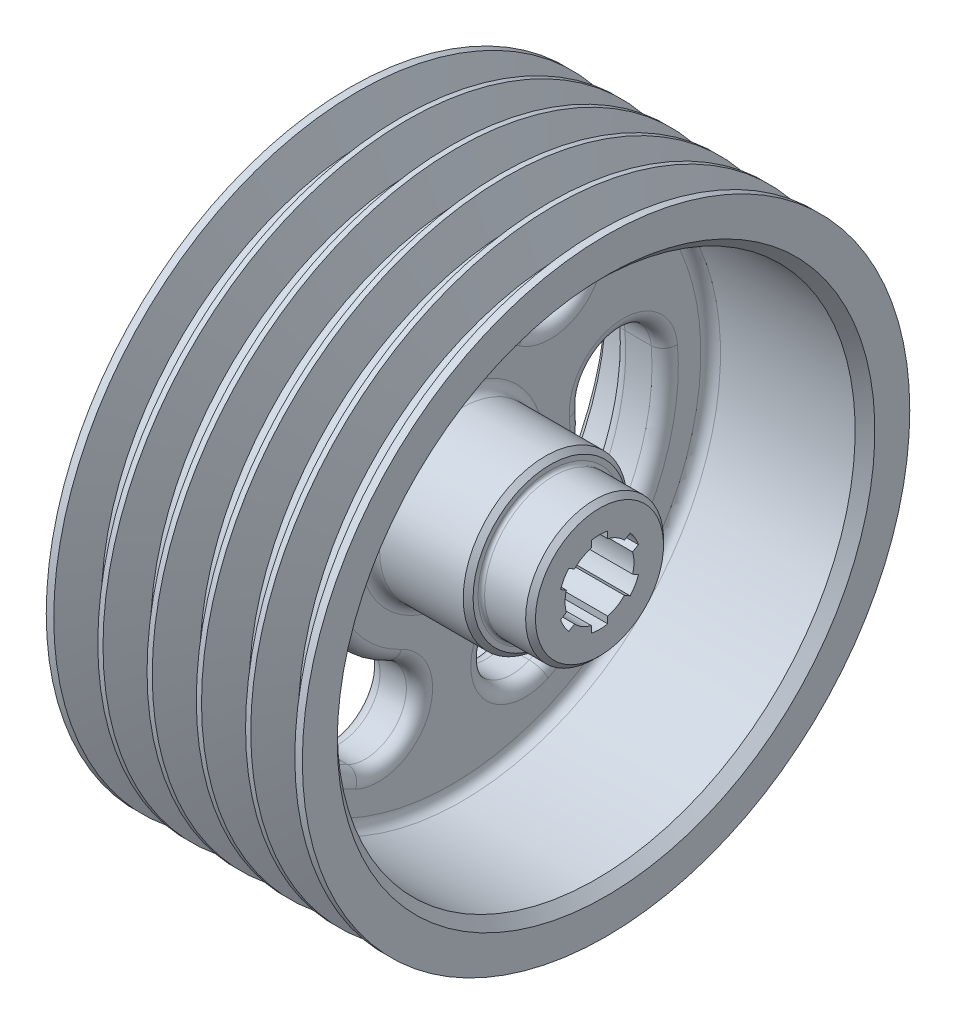
from build123d import *

# Parameters (mm, degrees)
CUT_EXTRUDE1_DEPTH = 77
CUT_EXTRUDE2_DEPTH = 32
CIRPATTERN1_COUNT  = 3
FILLET1_R          = 4


with BuildPart() as part:
    # Sketch1 → Revolve1 (revolve)
    with BuildSketch(Plane.XY):
        with BuildLine():
            Line((76, 0), (25, 0))
            Line((25, 0), (25, 12))
            ThreePointArc((25, 12), (24.707106781, 12.707106781), (24, 13))
            Line((24, 13), (15, 13))
            Line((15, 13), (15, 72))
            ThreePointArc((15, 72), (14.121320344, 74.121320344), (12, 75))
            Line((12, 75), (3, 75))
            Line((3, 75), (0, 78))
            Line((0, 78), (0, 92.5))
            Line((0, 92.5), (2.291591605, 92.5))
            Line((2.291591605, 92.5), (6, 81.73))
            Line((6, 81.73), (12, 81.73))
            Line((12, 81.73), (15.708408395, 92.5))
            Line((15.708408395, 92.5), (17.291591605, 92.5))
            Line((17.291591605, 92.5), (21, 81.73))
            Line((21, 81.73), (27, 81.73))
            Line((27, 81.73), (30.708408395, 92.5))
            Line((30.708408395, 92.5), (32.291591605, 92.5))
            Line((32.291591605, 92.5), (36, 81.73))
            Line((36, 81.73), (42, 81.73))
            Line((42, 81.73), (45.708408395, 92.5))
            Line((45.708408395, 92.5), (47.291591605, 92.5))
            Line((47.291591605, 92.5), (51, 81.73))
            Line((51, 81.73), (57, 81.73))
            Line((57, 81.73), (60.708408395, 92.5))
            Line((60.708408395, 92.5), (62.291591605, 92.5))
            Line((62.291591605, 92.5), (66, 81.73))
            Line((66, 81.73), (72, 81.73))
            Line((72, 81.73), (75.708408395, 92.5))
            Line((75.708408395, 92.5), (78, 92.5))
            Line((78, 92.5), (78, 81.865730979))
            Line((78, 81.865730979), (75, 78.865730979))
            Line((75, 78.865730979), (34, 78.865730979))
            ThreePointArc((34, 78.865730979), (31.878679656, 77.987051322), (31, 75.865730979))
            Line((31, 75.865730979), (31, 28))
            ThreePointArc((31, 28), (31.878679656, 25.878679656), (34, 25))
            Line((34, 25), (59.5, 25))
            Line((59.5, 25), (61, 23.5))
            Line((61, 23.5), (61, 22))
            ThreePointArc((61, 22), (61.292893219, 21.292893219), (62, 21))
            Line((62, 21), (74.5, 21))
            Line((74.5, 21), (76, 19.5))
            Line((76, 19.5), (76, 0))
        make_face()
    revolve(axis=Axis((-41.152890696, 0, 0), (1, 0, 0)))

    # Sketch2 → Cut-Extrude1 (cut, through all)
    with BuildSketch(Plane(origin=(76, 0, 0), x_dir=(0, 0, -1), z_dir=(1, 0, 0))):
        with BuildLine():
            Line((2.5, 12.247448714), (2.5, 10.198039027))
            ThreePointArc((2.5, 10.198039027), (5.25, 9.09326674), (7.581760866, 7.264083023))
            Line((7.581760866, 7.264083023), (9.356601718, 8.288787866))
            ThreePointArc((9.356601718, 8.288787866), (10.825317547, 6.25), (11.856601718, 3.958660847))
            Line((11.856601718, 3.958660847), (10.081760866, 2.933956004))
            ThreePointArc((10.081760866, 2.933956004), (10.5, 0), (10.081760866, -2.933956004))
            Line((10.081760866, -2.933956004), (11.856601718, -3.958660847))
            ThreePointArc((11.856601718, -3.958660847), (10.825317547, -6.25), (9.356601718, -8.288787866))
            Line((9.356601718, -8.288787866), (7.581760866, -7.264083023))
            ThreePointArc((7.581760866, -7.264083023), (5.25, -9.09326674), (2.5, -10.198039027))
            Line((2.5, -10.198039027), (2.5, -12.247448714))
            ThreePointArc((2.5, -12.247448714), (0, -12.5), (-2.5, -12.247448714))
            Line((-2.5, -12.247448714), (-2.5, -10.198039027))
            ThreePointArc((-2.5, -10.198039027), (-5.25, -9.09326674), (-7.581760866, -7.264083023))
            Line((-7.581760866, -7.264083023), (-9.356601718, -8.288787866))
            ThreePointArc((-9.356601718, -8.288787866), (-10.825317547, -6.25), (-11.856601718, -3.958660847))
            Line((-11.856601718, -3.958660847), (-10.081760866, -2.933956004))
            ThreePointArc((-10.081760866, -2.933956004), (-10.5, 0), (-10.081760866, 2.933956004))
            Line((-10.081760866, 2.933956004), (-11.856601718, 3.958660847))
            ThreePointArc((-11.856601718, 3.958660847), (-10.825317547, 6.25), (-9.356601718, 8.288787866))
            Line((-9.356601718, 8.288787866), (-7.581760866, 7.264083023))
            ThreePointArc((-7.581760866, 7.264083023), (-5.25, 9.09326674), (-2.5, 10.198039027))
            Line((-2.5, 10.198039027), (-2.5, 12.247448714))
            ThreePointArc((-2.5, 12.247448714), (0, 12.5), (2.5, 12.247448714))
        make_face()
    extrude(amount=-CUT_EXTRUDE1_DEPTH, mode=Mode.SUBTRACT)

    # Sketch3 → Cut-Extrude2 (cut, through all)
    with BuildSketch(Plane(origin=(31, 0, 0), x_dir=(0, 0, -1), z_dir=(1, 0, 0))):
        with BuildLine():
            ThreePointArc((37.142857143, 53.342367432), (0, 65), (-37.142857143, 53.342367432))
            ThreePointArc((-37.142857143, 53.342367432), (-40.258147583, 35.941362706), (-22.857142857, 32.826072266))
            ThreePointArc((-22.857142857, 32.826072266), (0, 40), (22.857142857, 32.826072266))
            ThreePointArc((22.857142857, 32.826072266), (40.258147583, 35.941362706), (37.142857143, 53.342367432))
        make_face()
    cut_extrude2 = extrude(amount=-CUT_EXTRUDE2_DEPTH, mode=Mode.SUBTRACT)

    # CirPattern1: Cut-Extrude2 ×3 about axis
    cirpattern1_axis = Axis((0, 0, 0), (1, 0, 0))
    for i in range(1, CIRPATTERN1_COUNT):
        add(cut_extrude2.rotate(cirpattern1_axis, i * 360 / CIRPATTERN1_COUNT), mode=Mode.SUBTRACT)

    # Fillet1
    fillet1_edges = [part.edges().sort_by_distance(p)[0] for p in [
        (15, 65, 0),
        (15, 35.941362706, 40.258147583),
        (15, 40, 0),
        (15, 35.941362706, -40.258147583),
        (31, 35.941362706, -40.258147583),
        (31, 65, 0),
        (31, 35.941362706, 40.258147583),
        (31, 40, 0),
        (15, -32.5, -56.291651246),
        (15, 16.893897163, -51.255206942),
        (15, -20, -34.641016151),
        (15, -52.835259869, -10.997059359),
        (15, -32.5, 56.291651246),
        (15, -52.835259869, 10.997059359),
        (15, -20, 34.641016151),
        (15, 16.893897163, 51.255206942),
        (31, 16.893897163, 51.255206942),
        (31, -32.5, 56.291651246),
        (31, -52.835259869, 10.997059359),
        (31, -20, 34.641016151),
        (31, -52.835259869, -10.997059359),
        (31, -32.5, -56.291651246),
        (31, 16.893897163, -51.255206942),
        (31, -20, -34.641016151),
    ]]
    fillet(fillet1_edges, radius=FILLET1_R)


solid = part.part
